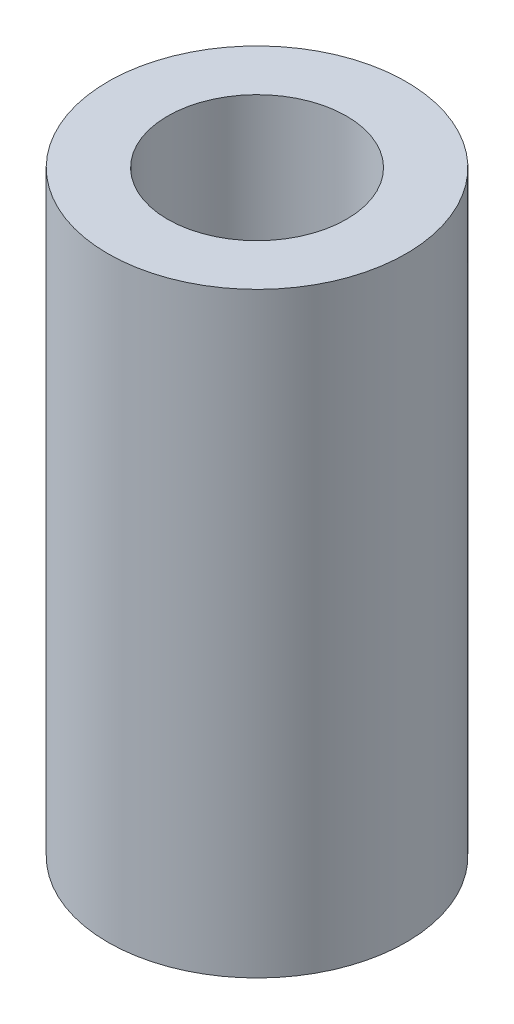
from build123d import *

# Parameters (mm, degrees)
SKETCH_1_R      = 3
EXTRUDE_1_DEPTH = 8
SKETCH_2_R      = 3
SKETCH_2_R_2    = 1.8
EXTRUDE_2_DEPTH = 4


with BuildPart() as part:
    # 草图1 → 凸台-拉伸1 (new body)
    with BuildSketch(Plane(origin=(0, 0, 0), x_dir=(1, 0, 0), z_dir=(0, 1, 0))):
        Circle(SKETCH_1_R)
        with BuildLine():
            ThreePointArc((1.24498996, -1.3), (0, 1.8), (-1.24498996, -1.3))
            Line((-1.24498996, -1.3), (1.24498996, -1.3))
        make_face(mode=Mode.SUBTRACT)
    extrude(amount=EXTRUDE_1_DEPTH)

    # 草图2 → 凸台-拉伸2 (add)
    with BuildSketch(Plane(origin=(0, 8, 0), x_dir=(1, 0, 0), z_dir=(0, 1, 0))):
        Circle(SKETCH_2_R)
        Circle(SKETCH_2_R_2, mode=Mode.SUBTRACT)
    extrude(amount=EXTRUDE_2_DEPTH)


solid = part.part
